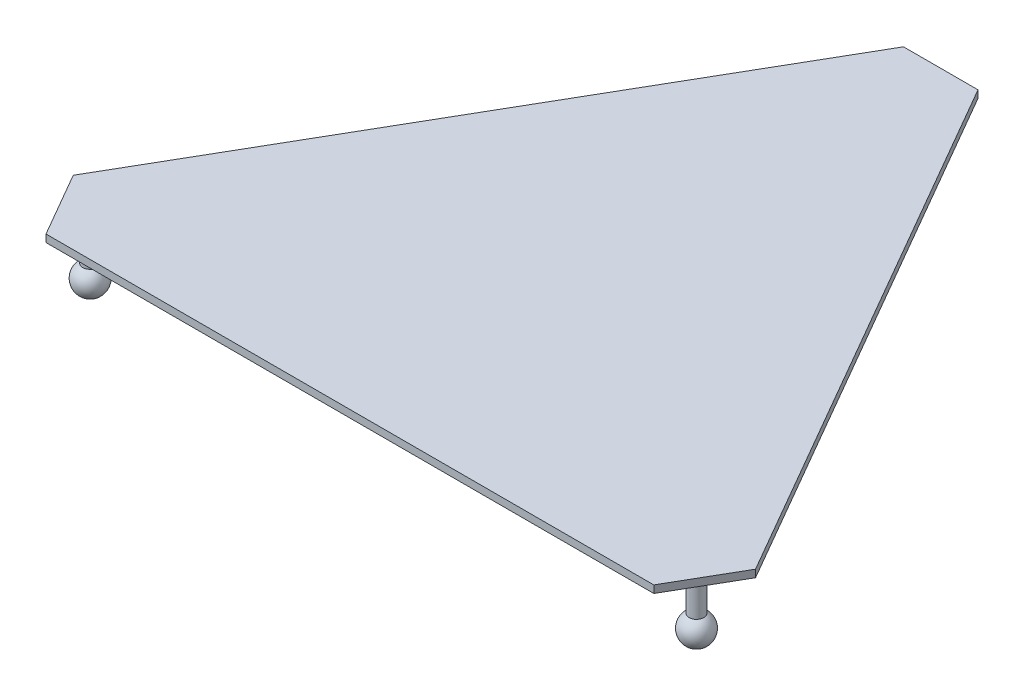
from build123d import *

# Parameters (mm, degrees)
SALIENTE_EXTRUIR1_DEPTH = 10
MATRIZC1_COUNT          = 3


with BuildPart() as part:
    # Croquis1 → Saliente-Extruir1 (new body)
    with BuildSketch(Plane(origin=(0, 0, 0), x_dir=(1, 0, 0), z_dir=(0, 1, 0))):
        Polygon((-50, 500), (50, 500), (458.012701892, -206.698729811), (408.012701892, -293.301270189), (-408.012701892, -293.301270189), (-458.012701892, -206.698729811), align=None)
    extrude(amount=SALIENTE_EXTRUIR1_DEPTH)

    # Croquis2 → Revolución1 (revolve)
    with BuildSketch(Plane(origin=(0, 0, 0), x_dir=(0, 0, -1), z_dir=(1, 0, 0))):
        with BuildLine():
            Line((470, 0), (470, -70))
            Line((470, -70), (470, -90))
            ThreePointArc((470, -90), (489.318516526, -75.176380902), (480, -52.679491924))
            Line((480, -52.679491924), (480, 0))
            Line((480, 0), (470, 0))
        make_face()
    revoluci_n1 = revolve(axis=Axis((0, 0, -470), (0, -1, 0)))

    # MatrizC1: Revolución1 ×3 about axis
    matrizc1_axis = Axis((0, 0, 0), (0, 1, 0))
    for i in range(1, MATRIZC1_COUNT):
        add(revoluci_n1.rotate(matrizc1_axis, i * 360 / MATRIZC1_COUNT))


solid = part.part
